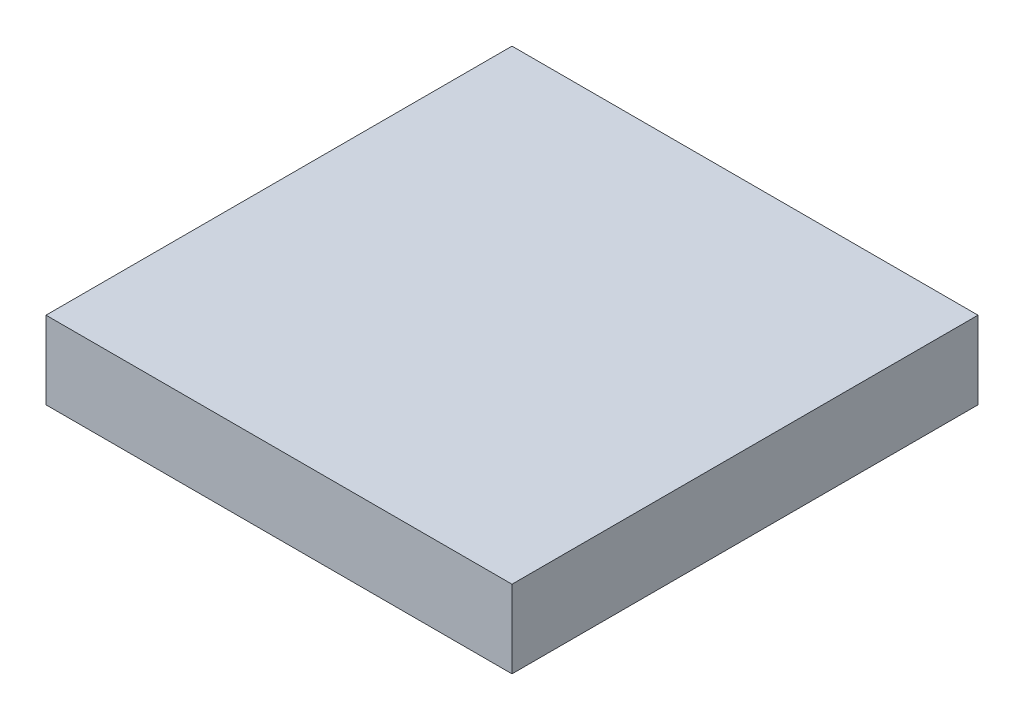
from build123d import *

# Parameters (mm, degrees)
SKETCH1_W           = 304.8
SKETCH1_H           = 304.8
BOSS_EXTRUDE1_DEPTH = 50.8


with BuildPart() as part:
    # Sketch1 → Boss-Extrude1 (new body)
    with BuildSketch(Plane(origin=(0, 0, 0), x_dir=(1, 0, 0), z_dir=(0, 1, 0))):
        Rectangle(SKETCH1_W, SKETCH1_H)
    extrude(amount=BOSS_EXTRUDE1_DEPTH)


solid = part.part
